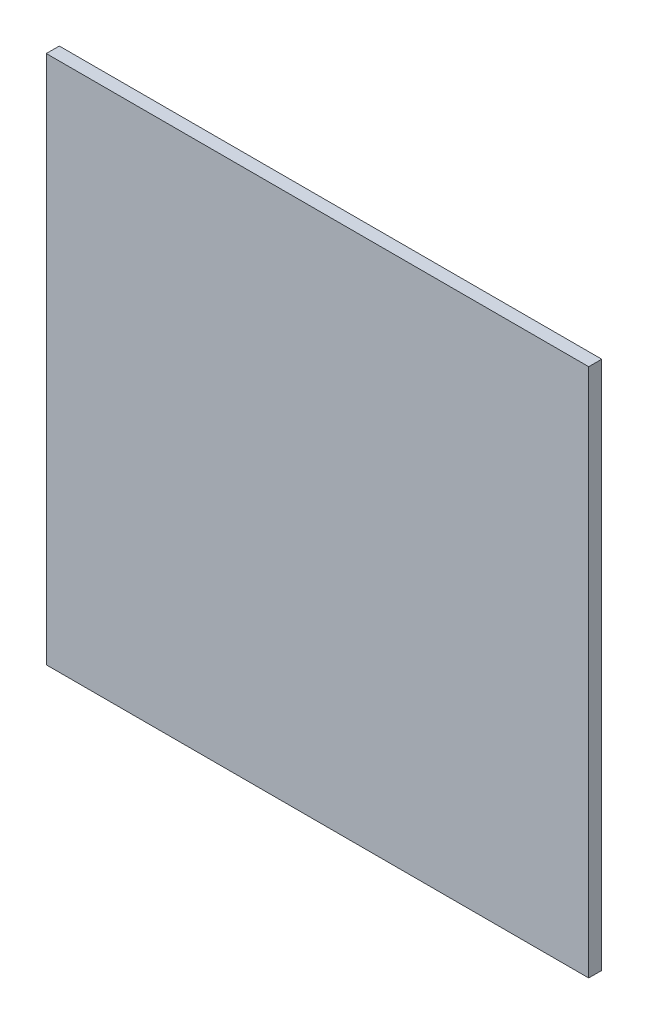
from build123d import *

# Parameters (mm, degrees)
SKETCH1_W           = 198.4375
SKETCH1_H           = 193.675
BOSS_EXTRUDE1_DEPTH = 4.7625


with BuildPart() as part:
    # Sketch1 → Boss-Extrude1 (new body)
    with BuildSketch(Plane.XY):
        Rectangle(SKETCH1_W, SKETCH1_H)
    extrude(amount=BOSS_EXTRUDE1_DEPTH)


solid = part.part
